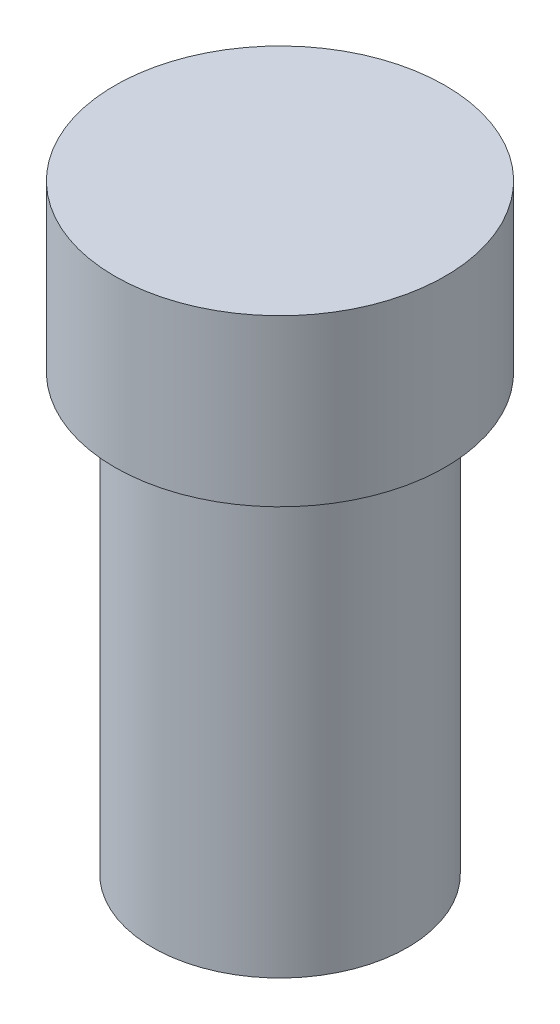
from build123d import *


with BuildPart() as part:
    # Sketch1 → Revolve1 (revolve)
    with BuildSketch(Plane.XY, mode=Mode.PRIVATE) as revolve1_sk:
        Polygon((0, -75), (-22, -75), (-22, 0), (-28.5, 0), (-28.5, 28.55085937), (0, 28.55085937), (0, 0), align=None)
    revolve(revolve1_sk.sketch.rotate(Axis((0, 0, 0), (0, 1, 0)), 270), axis=Axis((0, 0, 0), (0, 1, 0)))  # turned: the seam where the file's is


solid = part.part
